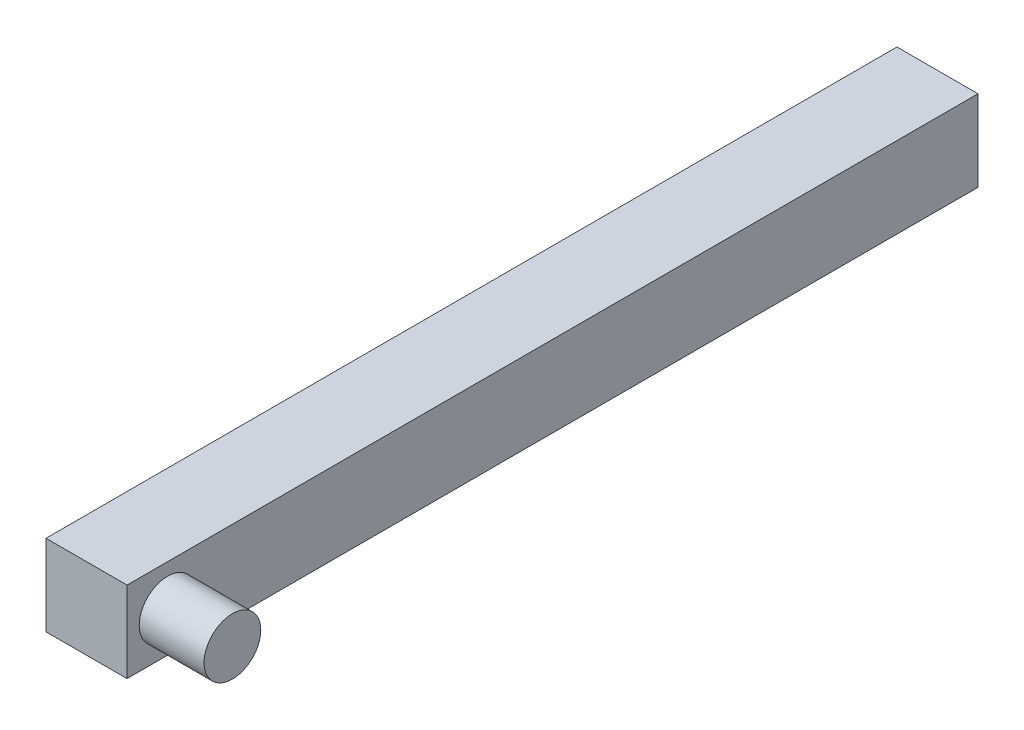
from build123d import *

# Parameters (mm, degrees)
SKETCH1_W           = 10
SKETCH1_H           = 10
BOSS_EXTRUDE1_DEPTH = 205
SKETCH2_R           = 3.5
BOSS_EXTRUDE2_DEPTH = 8
SKETCH4_W           = 10
SKETCH4_H           = 10
CUT_EXTRUDE1_DEPTH  = 100


with BuildPart() as part:
    # Sketch1 → Boss-Extrude1 (new body)
    with BuildSketch(Plane.XY):
        with Locations((5, -5)):
            Rectangle(SKETCH1_W, SKETCH1_H)
    extrude(amount=BOSS_EXTRUDE1_DEPTH)

    # Sketch2 → Boss-Extrude2 (add)
    with BuildSketch(Plane(origin=(10, 0, 0), x_dir=(0, 0, -1), z_dir=(1, 0, 0))):
        with Locations((-200, -5.053950804)):
            Circle(SKETCH2_R)
    extrude(amount=BOSS_EXTRUDE2_DEPTH)

    # Sketch4 → Cut-Extrude1 (cut)
    with BuildSketch(Plane(origin=(0, 0, 0), x_dir=(-1, 0, 0), z_dir=(0, 0, -1))):
        with Locations((-5, -5)):
            Rectangle(SKETCH4_W, SKETCH4_H)
    extrude(amount=-CUT_EXTRUDE1_DEPTH, mode=Mode.SUBTRACT)


solid = part.part
